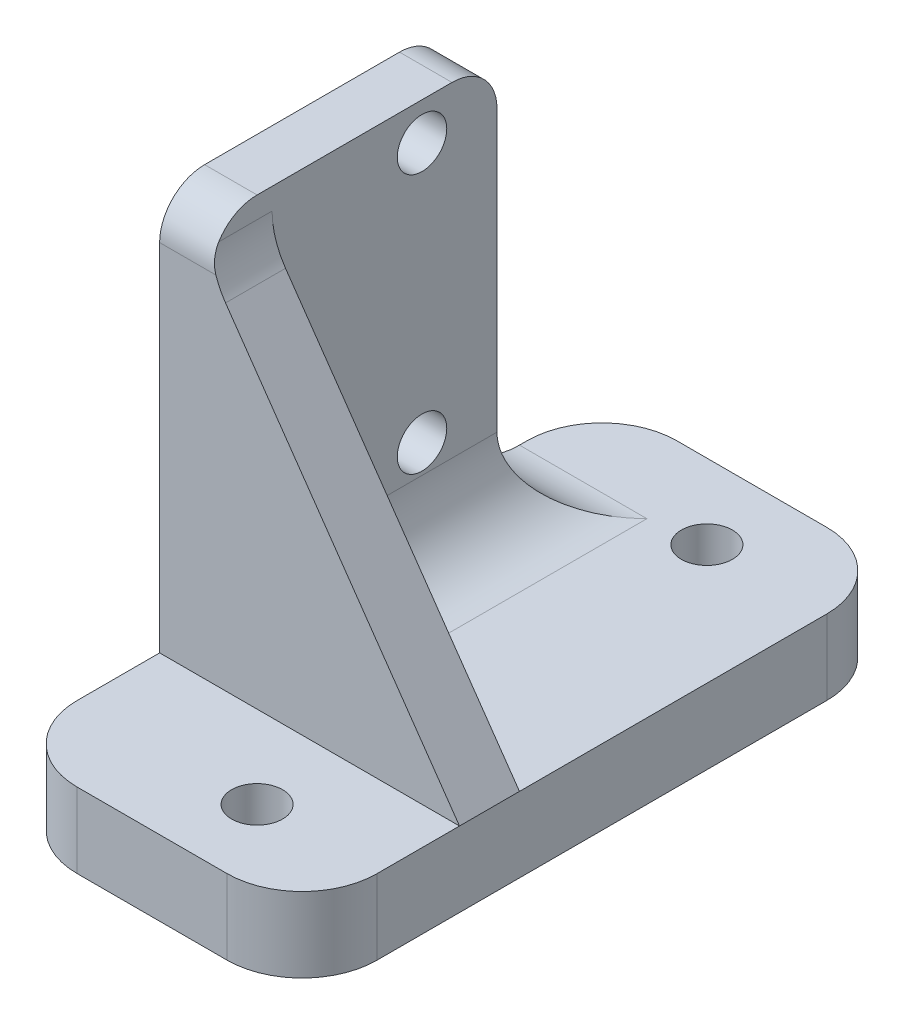
from build123d import *

# Parameters (mm, degrees)
SKETCH_1_W          = 20
SKETCH_1_H          = 40
EXTRUDE_1_DEPTH     = 5
SKETCH_2_W          = 19
SKETCH_2_H          = 26.7
EXTRUDE_2_DEPTH     = 3.5
SKETCH_3_R          = 1.65
CUT_EXTRUDE_1_DEPTH = 55.816876963
SKETCH_4_R          = 1.7
CUT_EXTRUDE_2_DEPTH = 53.085410625
FILLET_1_R          = 5
FILLET_2_R          = 3
RIB_1_REACH         = 49.698
SKETCH_5_WALL_W     = 126.274874616
SKETCH_5_WALL_H     = 4
FILLET_3_R          = 5


with BuildPart() as part:
    # 草图1 → 凸台-拉伸1 (new body)
    with BuildSketch(Plane(origin=(0, 0, 0), x_dir=(1, 0, 0), z_dir=(0, 1, 0))):
        with Locations((10, 20)):
            Rectangle(SKETCH_1_W, SKETCH_1_H)
    extrude(amount=EXTRUDE_1_DEPTH)

    # 草图2 → 凸台-拉伸2 (add)
    with BuildSketch(Plane.ZY):
        with Locations((-20, 18.35)):
            Rectangle(SKETCH_2_W, SKETCH_2_H)
    extrude(amount=-EXTRUDE_2_DEPTH)

    # 草图3 → 切除-拉伸1 (cut, through all)
    with BuildSketch(Plane.ZY):
        with Locations((-24.5, 29.2)):
            Circle(SKETCH_3_R)
        with Locations(Location((-24.5, 11.9, 0), (0, 0, 180))):
            Circle(SKETCH_3_R)
    extrude(amount=-CUT_EXTRUDE_1_DEPTH, mode=Mode.SUBTRACT)

    # 草图4 → 切除-拉伸2 (cut, through all)
    with BuildSketch(Plane(origin=(0, 5, 0), x_dir=(1, 0, 0), z_dir=(0, 1, 0))):
        with Locations(Location((12, 35, 0), (0, 0, 270))):
            Circle(SKETCH_4_R)
        with Locations(Location((12, 5, 0), (0, 0, 90))):
            Circle(SKETCH_4_R)
    extrude(amount=-CUT_EXTRUDE_2_DEPTH, mode=Mode.SUBTRACT)

    # 圆角1
    fillet_1_edges = [part.edges().sort_by_distance(p)[0] for p in [
        (0, 2.5, -40),
        (20, 2.5, -40),
        (20, 2.5, 0),
        (0, 2.5, 0),
    ]]
    fillet(fillet_1_edges, radius=FILLET_1_R)

    # 圆角2
    fillet_2_edges = [part.edges().sort_by_distance(p)[0] for p in [
        (1.75, 31.7, -29.5),
        (1.75, 31.7, -10.5),
    ]]
    fillet(fillet_2_edges, radius=FILLET_2_R)

    # 草图5 wall → 筋1 (add, up to next)
    with BuildSketch(Plane(origin=(11.75, 16.85, -10.5), x_dir=(0.571368826083, -0.820693404738, 0), z_dir=(0.820693404738, 0.571368826083, 0)), mode=Mode.PRIVATE) as rib_1_sk1:
        with Locations((0, 2)):
            Rectangle(SKETCH_5_WALL_W, SKETCH_5_WALL_H)
    rib_1_tool1 = extrude(rib_1_sk1.sketch, amount=-RIB_1_REACH, mode=Mode.PRIVATE) - part.part
    add(rib_1_tool1.solids().sort_by_distance((11.75, 16.85, -10.5))[0])

    # 圆角3
    fillet_3_edges = [part.edges().sort_by_distance(p)[0] for p in [
        (1.75, 5, -29.5),
        (3.5, 5, -22),
        (3.5, 28.7, -12.5),
    ]]
    fillet(fillet_3_edges, radius=FILLET_3_R)


solid = part.part
